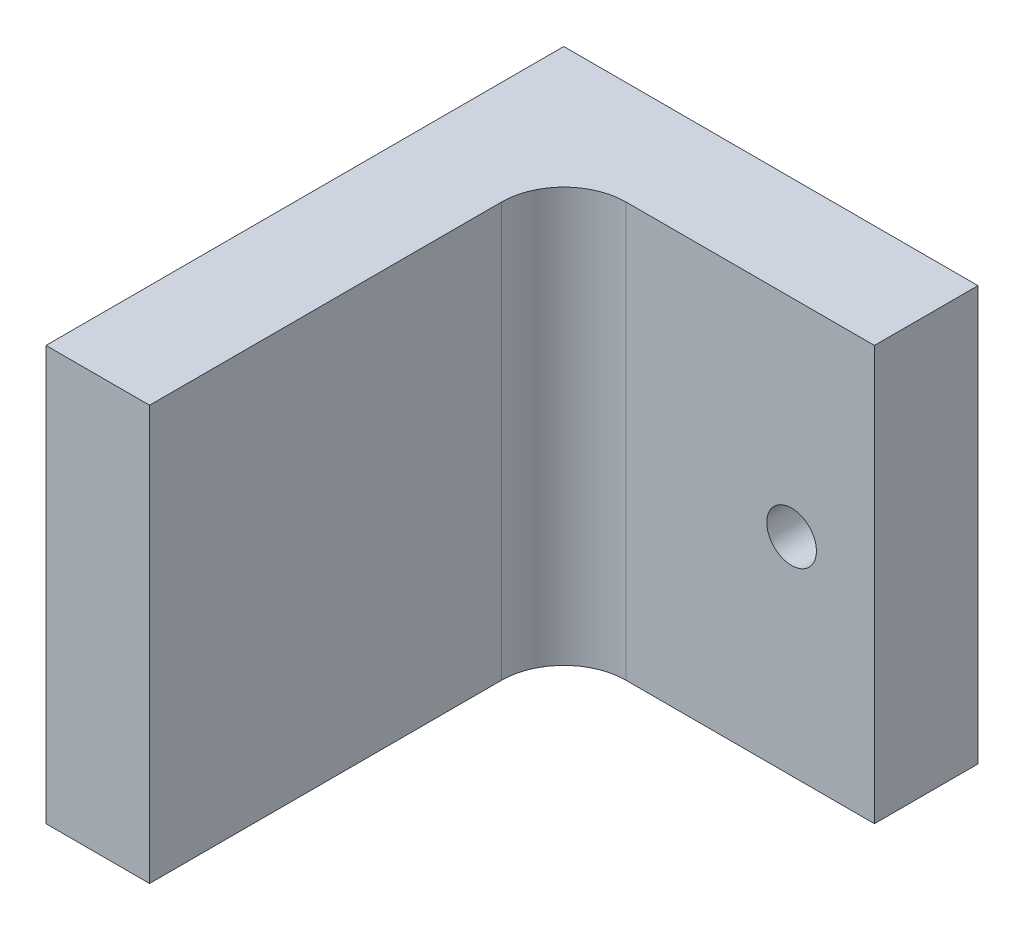
from build123d import *

# Parameters (mm, degrees)
SKETCH1_W           = 20
SKETCH1_H           = 20
BOSS_EXTRUDE1_DEPTH = 5
SKETCH2_W           = 5
SKETCH2_H           = 20
BOSS_EXTRUDE2_DEPTH = 20
FILLET1_R           = 3
SKETCH3_R           = 1.2
CUT_EXTRUDE1_DEPTH  = 20


with BuildPart() as part:
    # Sketch1 → Boss-Extrude1 (new body)
    with BuildSketch(Plane.XY):
        with Locations((10, 10)):
            Rectangle(SKETCH1_W, SKETCH1_H)
    extrude(amount=BOSS_EXTRUDE1_DEPTH)

    # Sketch2 → Boss-Extrude2 (add)
    with BuildSketch(Plane.XY.offset(5)):
        with Locations((2.5, 10)):
            Rectangle(SKETCH2_W, SKETCH2_H)
    extrude(amount=BOSS_EXTRUDE2_DEPTH)

    # Fillet1
    fillet1_edges = [part.edges().sort_by_distance(p)[0] for p in [
        (5, 10, 5),
    ]]
    fillet(fillet1_edges, radius=FILLET1_R)

    # Sketch3 → Cut-Extrude1 (cut)
    with BuildSketch(Plane(origin=(0, 0, 0), x_dir=(-1, 0, 0), z_dir=(0, 0, -1))):
        with Locations((-16, 10)):
            Circle(SKETCH3_R)
    extrude(amount=-CUT_EXTRUDE1_DEPTH, mode=Mode.SUBTRACT)


solid = part.part
